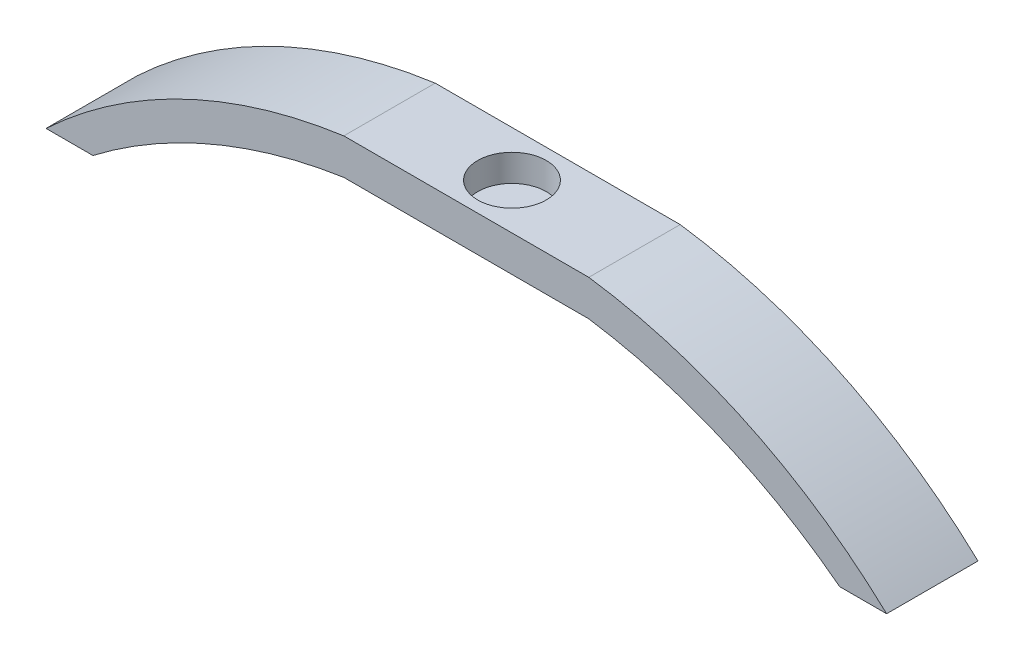
from build123d import *

# Parameters (mm, degrees)
SKETCH1_W           = 15.24
SKETCH1_H           = 10.16
BOSS_EXTRUDE1_DEPTH = 4
SKETCH2_R           = 3.81
CUT_EXTRUDE1_DEPTH  = 3
BOSS_EXTRUDE2_DEPTH = 10.16


with BuildPart() as part:
    # Sketch1 → Boss-Extrude1 (new body)
    with BuildSketch(Plane(origin=(0, 0, 0), x_dir=(1, 0, 0), z_dir=(0, 1, 0))):
        Rectangle(SKETCH1_W, SKETCH1_H)
    extrude(amount=BOSS_EXTRUDE1_DEPTH)

    # Sketch2 → Cut-Extrude1 (cut)
    with BuildSketch(Plane(origin=(0, 4, 0), x_dir=(1, 0, 0), z_dir=(0, 1, 0))):
        Circle(SKETCH2_R)
    extrude(amount=-CUT_EXTRUDE1_DEPTH, mode=Mode.SUBTRACT)

    # Sketch3 → Boss-Extrude2 (add)
    with BuildSketch(Plane.XY.offset(5.08)):
        with BuildLine():
            Line((13.62, 4), (7.62, 4))
            Line((7.62, 4), (7.62, 0))
            Line((7.62, 0), (13.62, 0))
            ThreePointArc((13.62, 0), (28.319939798, -4.147298344), (41.51503945, -11.84))
            Line((41.51503945, -11.84), (46.73503945, -11.84))
            ThreePointArc((46.73503945, -11.84), (31.406388408, -1.350932139), (13.62, 4))
        make_face()
        with BuildLine():
            ThreePointArc((-13.62, 4), (-31.406388408, -1.350932139), (-46.73503945, -11.84))
            Line((-46.73503945, -11.84), (-41.51503945, -11.84))
            ThreePointArc((-41.51503945, -11.84), (-28.319939798, -4.147298344), (-13.62, 0))
            Line((-13.62, 0), (-7.62, 0))
            Line((-7.62, 0), (-7.62, 4))
            Line((-7.62, 4), (-13.62, 4))
        make_face()
    extrude(amount=-BOSS_EXTRUDE2_DEPTH)


solid = part.part
